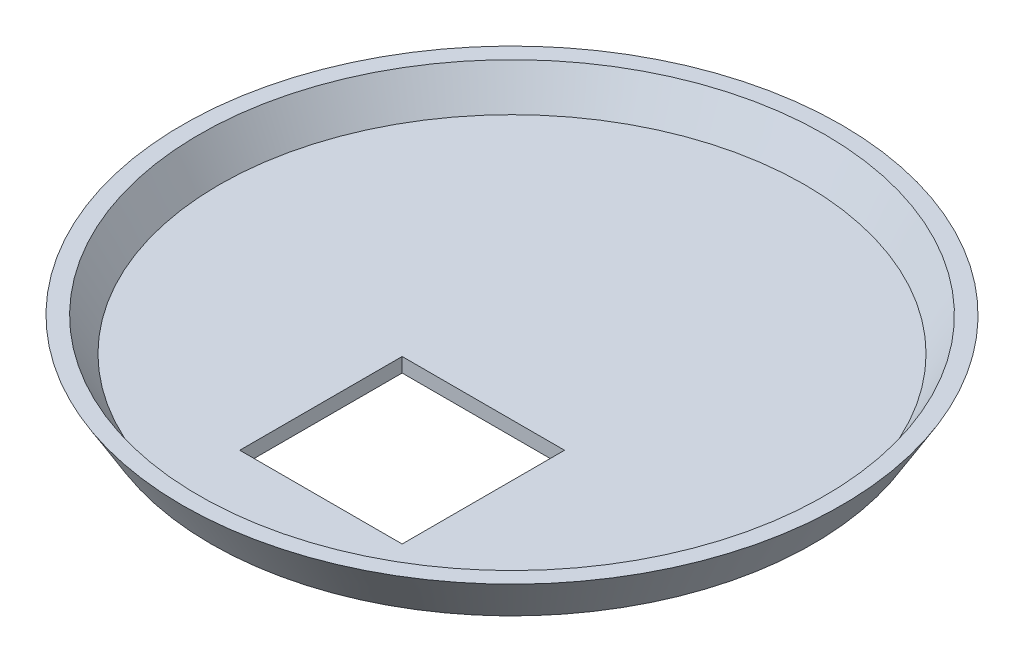
from build123d import *

# Parameters (mm, degrees)
SKETCH2_W          = 34
SKETCH2_H          = 34
CUT_EXTRUDE1_DEPTH = 11


with BuildPart() as part:
    # Sketch1 → Revolve1 (revolve)
    with BuildSketch(Plane.XY):
        Polygon((0, 0), (63, 0), (69, 10), (65.501428863, 10), (61.301428863, 3), (0, 3), align=None)
    revolve(axis=Axis((0, 0, 0), (0, 1, 0)))

    # Sketch2 → Cut-Extrude1 (cut, through all)
    with BuildSketch(Plane.XZ):
        with Locations((6, 29)):
            Rectangle(SKETCH2_W, SKETCH2_H)
    extrude(amount=-CUT_EXTRUDE1_DEPTH, mode=Mode.SUBTRACT)


solid = part.part
